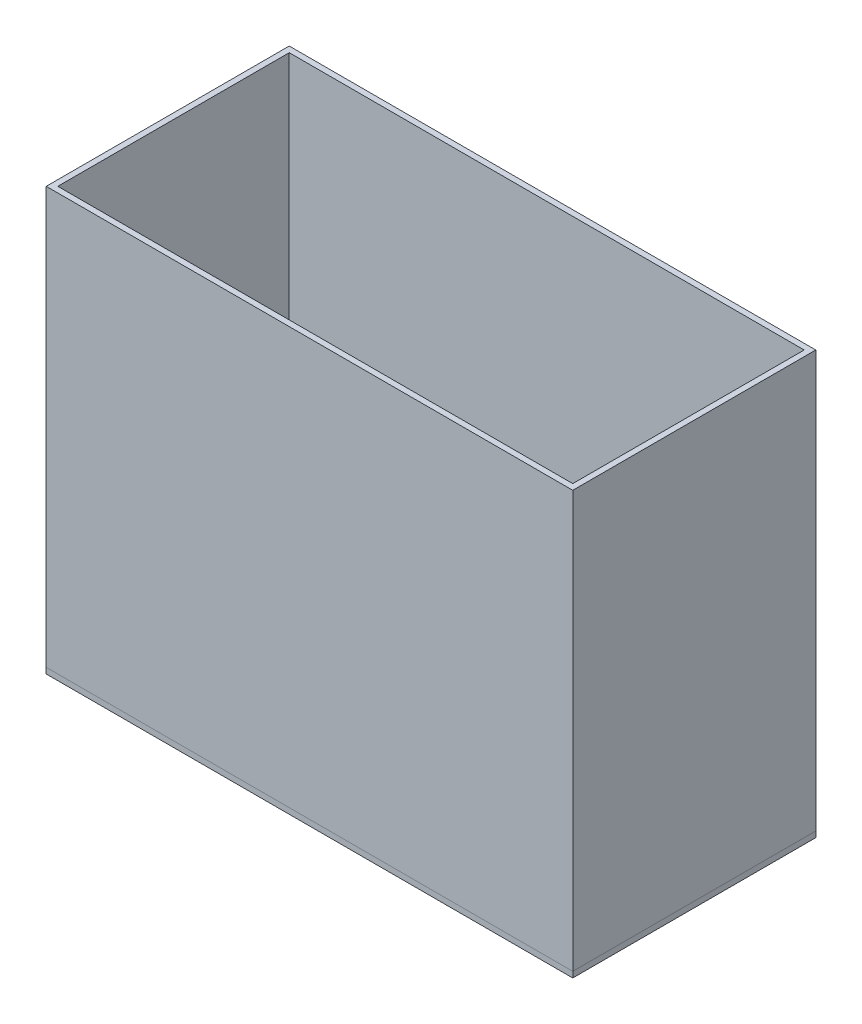
from build123d import *

# Parameters (mm, degrees)
SKETCH2_W           = 455
SKETCH2_H           = 210
SKETCH2_W_2         = 445
SKETCH2_H_2         = 200
BOSS_EXTRUDE1_DEPTH = 360
SKETCH3_W           = 455
SKETCH3_H           = 210
BOSS_EXTRUDE4_DEPTH = 5


with BuildPart() as part:
    # Sketch2 → Boss-Extrude1 (new body)
    with BuildSketch(Plane(origin=(0, 0, 0), x_dir=(1, 0, 0), z_dir=(0, 1, 0))):
        with Locations((-2.5, -5)):
            Rectangle(SKETCH2_W, SKETCH2_H)
        with Locations((-2.5, -5)):
            Rectangle(SKETCH2_W_2, SKETCH2_H_2, mode=Mode.SUBTRACT)
    extrude(amount=BOSS_EXTRUDE1_DEPTH)


with BuildPart() as body_2:
    # Sketch3 → Boss-Extrude4 (new body)
    with BuildSketch(Plane(origin=(0, 0, 0), x_dir=(1, 0, 0), z_dir=(0, 1, 0))):
        with Locations((-2.5, -5)):
            Rectangle(SKETCH3_W, SKETCH3_H)
    extrude(amount=-BOSS_EXTRUDE4_DEPTH)


solid = Compound([part.part, body_2.part])
